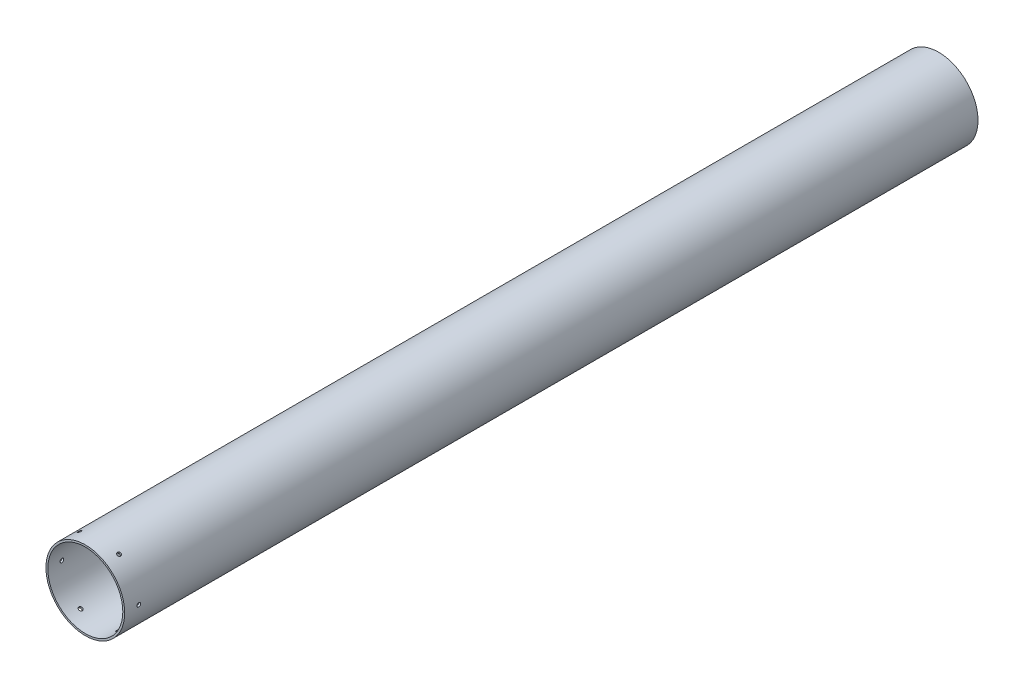
from build123d import *

# Parameters (mm, degrees)
SKETCH3_R           = 42
SKETCH3_R_2         = 40
BOSS_EXTRUDE1_DEPTH = 910
CUT_EXTRUDE1_START  = -2.050031
SKETCH4_R           = 2
CUT_EXTRUDE1_DEPTH  = 2.050031
CIRPATTERN1_COUNT   = 6


with BuildPart() as part:
    # Sketch3 → Boss-Extrude1 (new body)
    with BuildSketch(Plane.XY.offset(455)):
        Circle(SKETCH3_R)
        Circle(SKETCH3_R_2, mode=Mode.SUBTRACT)
    extrude(amount=-BOSS_EXTRUDE1_DEPTH)

    # Sketch4 → Cut-Extrude1 (cut)
    with BuildSketch(Plane(origin=(42, 0, 0), x_dir=(0, 0, -1), z_dir=(1, 0, 0)).offset(CUT_EXTRUDE1_START)):
        with Locations((-440, 0)):
            Circle(SKETCH4_R)
    cut_extrude1 = extrude(amount=CUT_EXTRUDE1_DEPTH, mode=Mode.SUBTRACT)

    # CirPattern1: Cut-Extrude1 ×6 about axis
    cirpattern1_axis = Axis((0, 0, 455), (0, 0, 1))
    for i in range(1, CIRPATTERN1_COUNT):
        add(cut_extrude1.rotate(cirpattern1_axis, i * 360 / CIRPATTERN1_COUNT), mode=Mode.SUBTRACT)


solid = part.part
